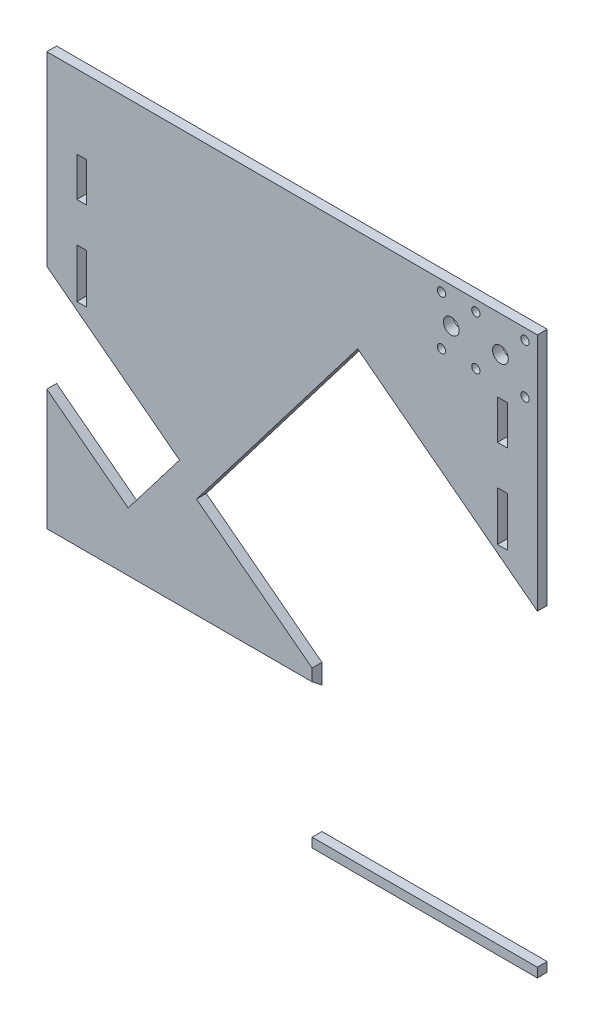
from build123d import *

# Parameters (mm, degrees)
SKETCH1_W           = 249.6
SKETCH1_H           = 283.36
BOSS_EXTRUDE1_DEPTH = 5
SKETCH3_W           = 135
SKETCH3_H           = 230.014345446
CUT_EXTRUDE1_DEPTH  = 193
CUT_EXTRUDE2_DEPTH  = 6
CUT_EXTRUDE3_DEPTH  = 6
SKETCH6_R           = 2.1
SKETCH6_R_2         = 4
CUT_EXTRUDE4_DEPTH  = 6
SKETCH7_W           = 5
SKETCH7_H           = 20
SKETCH7_H_2         = 25
CUT_EXTRUDE5_DEPTH  = 6


with BuildPart() as part:
    # Sketch1 → Boss-Extrude1 (new body)
    with BuildSketch(Plane.XY):
        with Locations((124.8, -141.68)):
            Rectangle(SKETCH1_W, SKETCH1_H)
    extrude(amount=BOSS_EXTRUDE1_DEPTH)

    # Sketch3 → Cut-Extrude1 (cut)
    with BuildSketch(Plane(origin=(0, -132.940025556, 103.864131154), x_dir=(1, 0, 0), z_dir=(0, 0.788010754, -0.615661475))):
        with Locations((67.5, 103.601456608)):
            Rectangle(SKETCH3_W, SKETCH3_H)
    extrude(amount=-CUT_EXTRUDE1_DEPTH, mode=Mode.SUBTRACT)

    # Sketch4 → Cut-Extrude2 (cut, through all)
    with BuildSketch(Plane.XY.offset(5)):
        Polygon((214.957001473, -95.278291976), (249.6, -121.767183305), (249.6, -278.612119258), (135, -278.612119258), (135, -204.083134422), (76.149175745, -159.084342324), (158.149444505, -51.841832454), align=None)
    extrude(amount=-CUT_EXTRUDE2_DEPTH, mode=Mode.SUBTRACT)

    # Sketch5 → Cut-Extrude3 (cut, through all)
    with BuildSketch(Plane.XY.offset(5)):
        Polygon((0, -94.564658056), (67.52306177, -146.194456905), (41.404457646, -180.353182271), (-26.118604124, -128.723383422), align=None)
    extrude(amount=-CUT_EXTRUDE3_DEPTH, mode=Mode.SUBTRACT)

    # Sketch6 → Cut-Extrude4 (cut, through all)
    with BuildSketch(Plane.XY.offset(5)):
        with Locations((243.3, -5.5)):
            Circle(SKETCH6_R)
        with Locations((243.3, -30.5)):
            Circle(SKETCH6_R)
        with Locations((218.3, -30.5)):
            Circle(SKETCH6_R)
        with Locations((218.3, -5.5)):
            Circle(SKETCH6_R)
        with Locations((200.8, -30.5)):
            Circle(SKETCH6_R)
        with Locations((200.8, -5.5)):
            Circle(SKETCH6_R)
        with Locations((205.8, -18)):
            Circle(SKETCH6_R_2)
        with Locations((230.8, -18)):
            Circle(SKETCH6_R_2)
    extrude(amount=-CUT_EXTRUDE4_DEPTH, mode=Mode.SUBTRACT)

    # Sketch7 → Cut-Extrude5 (cut, through all)
    with BuildSketch(Plane.XY.offset(5)):
        with Locations((17.788155616, -47.477871486)):
            Rectangle(SKETCH7_W, SKETCH7_H)
        with Locations((231.811844384, -47.477871486)):
            Rectangle(SKETCH7_W, SKETCH7_H)
        with Locations((17.788155616, -89.977871486)):
            Rectangle(SKETCH7_W, SKETCH7_H_2)
        with Locations((231.811844384, -89.977871486)):
            Rectangle(SKETCH7_W, SKETCH7_H_2)
    extrude(amount=-CUT_EXTRUDE5_DEPTH, mode=Mode.SUBTRACT)


solid = part.part
